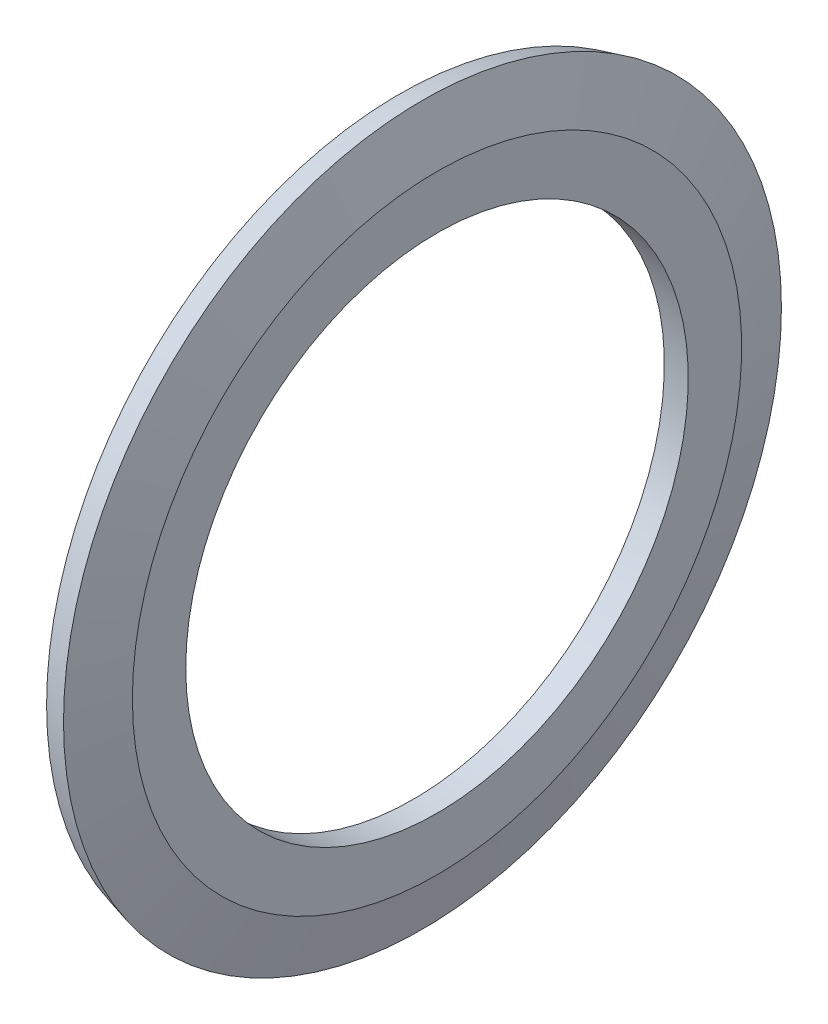
from build123d import *


with BuildPart() as part:
    # Sketch1 → Revolve1 (revolve)
    with BuildSketch(Plane.XY):
        Polygon((0, 10.5), (0, 12.598347502), (-0.574170493, 14.741180955), (0.391755333, 15), (1, 12.73), (1, 10.5), align=None)
    revolve(axis=Axis((0, 0, 0), (1, 0, 0)))


solid = part.part
